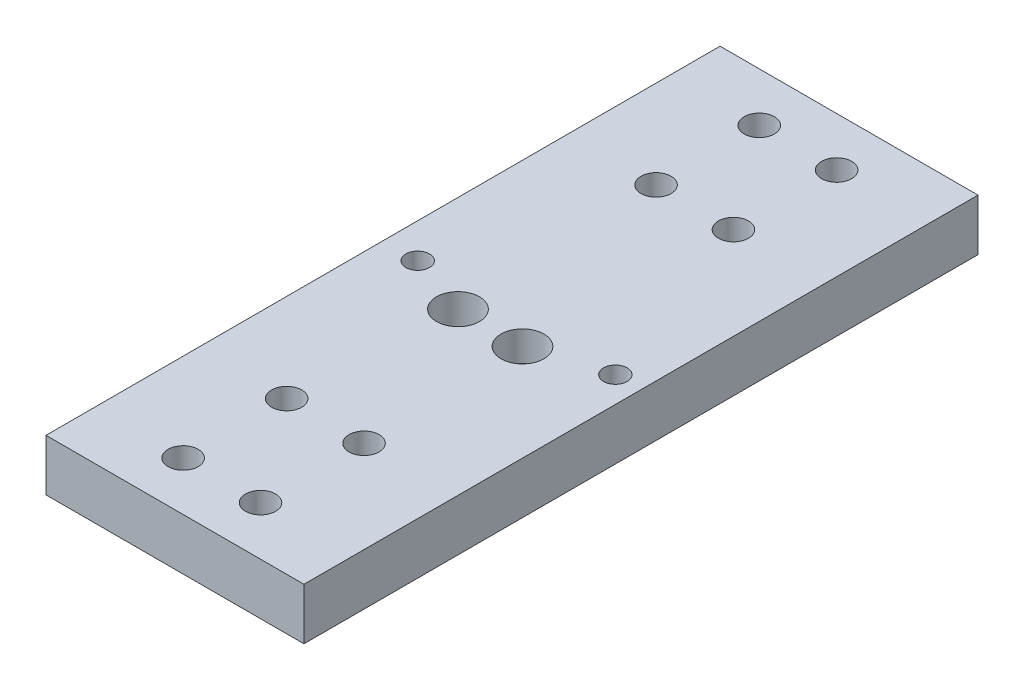
from build123d import *

# Parameters (mm, degrees)
SKETCH3_W           = 156.772980402
SKETCH3_H           = 60
BOSS_EXTRUDE6_DEPTH = 12
CUT_EXTRUDE1_REACH  = 14
SKETCH4_R           = 2.25
CUT_EXTRUDE2_REACH  = 14
SKETCH6_R           = 3.25
SKETCH7_R           = 3.5
CUT_EXTRUDE3_DEPTH  = 5
SKETCH8_R           = 5
CUT_EXTRUDE4_DEPTH  = 7
CUT_EXTRUDE5_REACH  = 14
SKETCH9_R           = 2.75


with BuildPart() as part:
    # Sketch3 → Boss-Extrude6 (new body)
    with BuildSketch(Plane(origin=(-27.52701042, 0, 0), x_dir=(0, 0, 1), z_dir=(0, 1, 0))):
        with Locations((-23.695908121, 17.809773729)):
            Rectangle(SKETCH3_W, SKETCH3_H)
    extrude(amount=BOSS_EXTRUDE6_DEPTH)

    # Sketch4 → Cut-Extrude1 (cut, up to next)
    with BuildSketch(Plane(origin=(0, 12, 0), x_dir=(1, 0, 0), z_dir=(0, 1, 0)), mode=Mode.PRIVATE) as cut_extrude1_sk1:
        with Locations((-1.126993796, -19.304091879)):
            Circle(SKETCH4_R)
    cut_extrude1_tool1 = extrude(cut_extrude1_sk1.sketch, amount=-CUT_EXTRUDE1_REACH, mode=Mode.PRIVATE) & part.part
    add(cut_extrude1_tool1.solids().sort_by_distance((-1.126994, 12, 19.304092))[0], mode=Mode.SUBTRACT)
    # Sketch4 → Cut-Extrude1 (cut, up to next)
    with BuildSketch(Plane(origin=(0, 12, 0), x_dir=(1, 0, 0), z_dir=(0, 1, 0)), mode=Mode.PRIVATE) as cut_extrude1_sk2:
        with Locations((-19.127096376, -19.304091879)):
            Circle(SKETCH4_R)
    cut_extrude1_tool2 = extrude(cut_extrude1_sk2.sketch, amount=-CUT_EXTRUDE1_REACH, mode=Mode.PRIVATE) & part.part
    add(cut_extrude1_tool2.solids().sort_by_distance((-19.127096, 12, 19.304092))[0], mode=Mode.SUBTRACT)
    # Sketch4 → Cut-Extrude1 (cut, up to next)
    with BuildSketch(Plane(origin=(0, 12, 0), x_dir=(1, 0, 0), z_dir=(0, 1, 0)), mode=Mode.PRIVATE) as cut_extrude1_sk3:
        with Locations((-1.2080193, -43.304091879)):
            Circle(SKETCH4_R)
    cut_extrude1_tool3 = extrude(cut_extrude1_sk3.sketch, amount=-CUT_EXTRUDE1_REACH, mode=Mode.PRIVATE) & part.part
    add(cut_extrude1_tool3.solids().sort_by_distance((-1.208019, 12, 43.304092))[0], mode=Mode.SUBTRACT)
    # Sketch4 → Cut-Extrude1 (cut, up to next)
    with BuildSketch(Plane(origin=(0, 12, 0), x_dir=(1, 0, 0), z_dir=(0, 1, 0)), mode=Mode.PRIVATE) as cut_extrude1_sk4:
        with Locations((-19.208121879, -43.304091879)):
            Circle(SKETCH4_R)
    cut_extrude1_tool4 = extrude(cut_extrude1_sk4.sketch, amount=-CUT_EXTRUDE1_REACH, mode=Mode.PRIVATE) & part.part
    add(cut_extrude1_tool4.solids().sort_by_distance((-19.208122, 12, 43.304092))[0], mode=Mode.SUBTRACT)
    # Sketch4 → Cut-Extrude1 (cut, up to next)
    with BuildSketch(Plane(origin=(0, 12, 0), x_dir=(1, 0, 0), z_dir=(0, 1, 0)), mode=Mode.PRIVATE) as cut_extrude1_sk5:
        with Locations((-19.208121879, 66.695908121)):
            Circle(SKETCH4_R)
    cut_extrude1_tool5 = extrude(cut_extrude1_sk5.sketch, amount=-CUT_EXTRUDE1_REACH, mode=Mode.PRIVATE) & part.part
    add(cut_extrude1_tool5.solids().sort_by_distance((-19.208122, 12, -66.695908))[0], mode=Mode.SUBTRACT)
    # Sketch4 → Cut-Extrude1 (cut, up to next)
    with BuildSketch(Plane(origin=(0, 12, 0), x_dir=(1, 0, 0), z_dir=(0, 1, 0)), mode=Mode.PRIVATE) as cut_extrude1_sk6:
        with Locations((-19.208121879, 90.695908121)):
            Circle(SKETCH4_R)
    cut_extrude1_tool6 = extrude(cut_extrude1_sk6.sketch, amount=-CUT_EXTRUDE1_REACH, mode=Mode.PRIVATE) & part.part
    add(cut_extrude1_tool6.solids().sort_by_distance((-19.208122, 12, -90.695908))[0], mode=Mode.SUBTRACT)
    # Sketch4 → Cut-Extrude1 (cut, up to next)
    with BuildSketch(Plane(origin=(0, 12, 0), x_dir=(1, 0, 0), z_dir=(0, 1, 0)), mode=Mode.PRIVATE) as cut_extrude1_sk7:
        with Locations((-1.2080193, 90.695908121)):
            Circle(SKETCH4_R)
    cut_extrude1_tool7 = extrude(cut_extrude1_sk7.sketch, amount=-CUT_EXTRUDE1_REACH, mode=Mode.PRIVATE) & part.part
    add(cut_extrude1_tool7.solids().sort_by_distance((-1.208019, 12, -90.695908))[0], mode=Mode.SUBTRACT)
    # Sketch4 → Cut-Extrude1 (cut, up to next)
    with BuildSketch(Plane(origin=(0, 12, 0), x_dir=(1, 0, 0), z_dir=(0, 1, 0)), mode=Mode.PRIVATE) as cut_extrude1_sk8:
        with Locations((-1.2080193, 66.695908121)):
            Circle(SKETCH4_R)
    cut_extrude1_tool8 = extrude(cut_extrude1_sk8.sketch, amount=-CUT_EXTRUDE1_REACH, mode=Mode.PRIVATE) & part.part
    add(cut_extrude1_tool8.solids().sort_by_distance((-1.208019, 12, -66.695908))[0], mode=Mode.SUBTRACT)

    # Sketch6 → Cut-Extrude2 (cut, up to next)
    with BuildSketch(Plane(origin=(0, 12, 0), x_dir=(1, 0, 0), z_dir=(0, 1, 0)), mode=Mode.PRIVATE) as cut_extrude2_sk1:
        with Locations((-17.217236691, 18.631632081)):
            Circle(SKETCH6_R)
    cut_extrude2_tool1 = extrude(cut_extrude2_sk1.sketch, amount=-CUT_EXTRUDE2_REACH, mode=Mode.PRIVATE) & part.part
    add(cut_extrude2_tool1.solids().sort_by_distance((-17.217237, 12, -18.631632))[0], mode=Mode.SUBTRACT)
    # Sketch6 → Cut-Extrude2 (cut, up to next)
    with BuildSketch(Plane(origin=(0, 12, 0), x_dir=(1, 0, 0), z_dir=(0, 1, 0)), mode=Mode.PRIVATE) as cut_extrude2_sk2:
        with Locations((-2.217236691, 18.631632081)):
            Circle(SKETCH6_R)
    cut_extrude2_tool2 = extrude(cut_extrude2_sk2.sketch, amount=-CUT_EXTRUDE2_REACH, mode=Mode.PRIVATE) & part.part
    add(cut_extrude2_tool2.solids().sort_by_distance((-2.217237, 12, -18.631632))[0], mode=Mode.SUBTRACT)

    # Sketch7 → Cut-Extrude3 (cut)
    with BuildSketch(Plane(origin=(0, 12, 0), x_dir=(1, 0, 0), z_dir=(0, 1, 0))):
        with Locations((-19.127096376, -19.304091879)):
            Circle(SKETCH7_R)
        with Locations((-19.208121879, -43.304091879)):
            Circle(SKETCH7_R)
        with Locations((-1.2080193, -43.304091879)):
            Circle(SKETCH7_R)
        with Locations((-1.126993796, -19.304091879)):
            Circle(SKETCH7_R)
        with Locations((-1.2080193, 66.695908121)):
            Circle(SKETCH7_R)
        with Locations((-19.208121879, 66.695908121)):
            Circle(SKETCH7_R)
        with Locations((-19.208121879, 90.695908121)):
            Circle(SKETCH7_R)
        with Locations((-1.2080193, 90.695908121)):
            Circle(SKETCH7_R)
    extrude(amount=-CUT_EXTRUDE3_DEPTH, mode=Mode.SUBTRACT)

    # Sketch8 → Cut-Extrude4 (cut)
    with BuildSketch(Plane(origin=(0, 12, 0), x_dir=(1, 0, 0), z_dir=(0, 1, 0))):
        with Locations((-17.217236691, 18.631632081)):
            Circle(SKETCH8_R)
        with Locations((-2.217236691, 18.631632081)):
            Circle(SKETCH8_R)
    extrude(amount=-CUT_EXTRUDE4_DEPTH, mode=Mode.SUBTRACT)

    # Sketch9 → Cut-Extrude5 (cut, up to next)
    with BuildSketch(Plane(origin=(0, 12, 0), x_dir=(1, 0, 0), z_dir=(0, 1, 0)), mode=Mode.PRIVATE) as cut_extrude5_sk1:
        with Locations((-31.657880115, 23.701844607)):
            Circle(SKETCH9_R)
    cut_extrude5_tool1 = extrude(cut_extrude5_sk1.sketch, amount=-CUT_EXTRUDE5_REACH, mode=Mode.PRIVATE) & part.part
    add(cut_extrude5_tool1.solids().sort_by_distance((-31.65788, 12, -23.701845))[0], mode=Mode.SUBTRACT)
    # Sketch9 → Cut-Extrude5 (cut, up to next)
    with BuildSketch(Plane(origin=(0, 12, 0), x_dir=(1, 0, 0), z_dir=(0, 1, 0)), mode=Mode.PRIVATE) as cut_extrude5_sk2:
        with Locations((14.282732382, 23.735684254)):
            Circle(SKETCH9_R)
    cut_extrude5_tool2 = extrude(cut_extrude5_sk2.sketch, amount=-CUT_EXTRUDE5_REACH, mode=Mode.PRIVATE) & part.part
    add(cut_extrude5_tool2.solids().sort_by_distance((14.282732, 12, -23.735684))[0], mode=Mode.SUBTRACT)


solid = part.part
